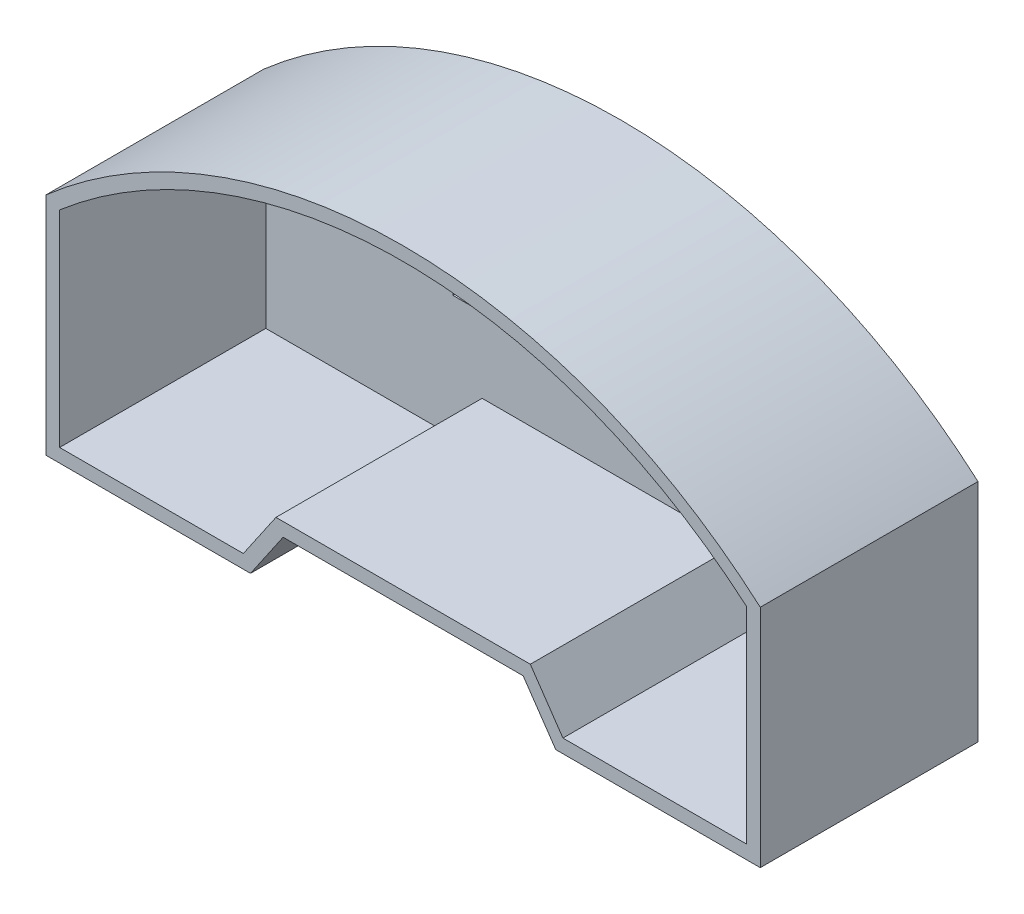
from build123d import *

# Parameters (mm, degrees)
SKETCH2_W           = 15.24
SKETCH2_H           = 20.32
BOSS_EXTRUDE4_DEPTH = 2.159
EXTRUDE_THIN2_DEPTH = 40.64


with BuildPart() as part:
    # Sketch2 → Boss-Extrude4 (new body)
    with BuildSketch(Plane.XY):
        with BuildLine():
            Line((166.65702, 132.382444359), (166.65702, 93.98))
            Line((166.65702, 93.98), (200.94702, 93.98))
            Line((200.94702, 93.98), (207.037726035, 102.87))
            Line((207.037726035, 102.87), (254.512766428, 102.87))
            Line((254.512766428, 102.87), (260.603472462, 93.98))
            Line((260.603472462, 93.98), (294.893472462, 93.98))
            Line((294.893472462, 93.98), (294.893472462, 132.382444359))
            ThreePointArc((294.893472462, 132.382444359), (230.775246231, 156.110938615), (166.65702, 132.382444359))
        make_face()
        with Locations((252.365246231, 126.944020361)):
            Rectangle(SKETCH2_W, SKETCH2_H, mode=Mode.SUBTRACT)
        with Locations((209.185246231, 126.944020361)):
            Rectangle(SKETCH2_W, SKETCH2_H, mode=Mode.SUBTRACT)
        with Locations((230.775246231, 126.944020361)):
            Rectangle(SKETCH2_W, SKETCH2_H, mode=Mode.SUBTRACT)
    extrude(amount=BOSS_EXTRUDE4_DEPTH)

    # Sketch2_7 → Extrude-Thin2 (add)
    with BuildSketch(Plane.XY):
        with BuildLine():
            Line((164.11702, 133.541292), (164.11702, 91.44))
            Line((164.11702, 91.44), (202.285763232, 91.44))
            Line((202.285763232, 91.44), (208.376469266, 100.33))
            Line((208.376469266, 100.33), (253.174023196, 100.33))
            Line((253.174023196, 100.33), (259.264729231, 91.44))
            Line((259.264729231, 91.44), (297.433472462, 91.44))
            Line((297.433472462, 91.44), (297.433472462, 133.541292))
            ThreePointArc((297.433472462, 133.541292), (230.775246231, 158.650938615), (164.11702, 133.541292))
        make_face()
        with BuildLine():
            Line((166.65702, 132.382444359), (166.65702, 93.98))
            Line((166.65702, 93.98), (200.94702, 93.98))
            Line((200.94702, 93.98), (207.037726035, 102.87))
            Line((207.037726035, 102.87), (254.512766428, 102.87))
            Line((254.512766428, 102.87), (260.603472462, 93.98))
            Line((260.603472462, 93.98), (294.893472462, 93.98))
            Line((294.893472462, 93.98), (294.893472462, 132.382444359))
            ThreePointArc((294.893472462, 132.382444359), (230.775246231, 156.110938615), (166.65702, 132.382444359))
        make_face(mode=Mode.SUBTRACT)
    extrude(amount=EXTRUDE_THIN2_DEPTH)


solid = part.part
